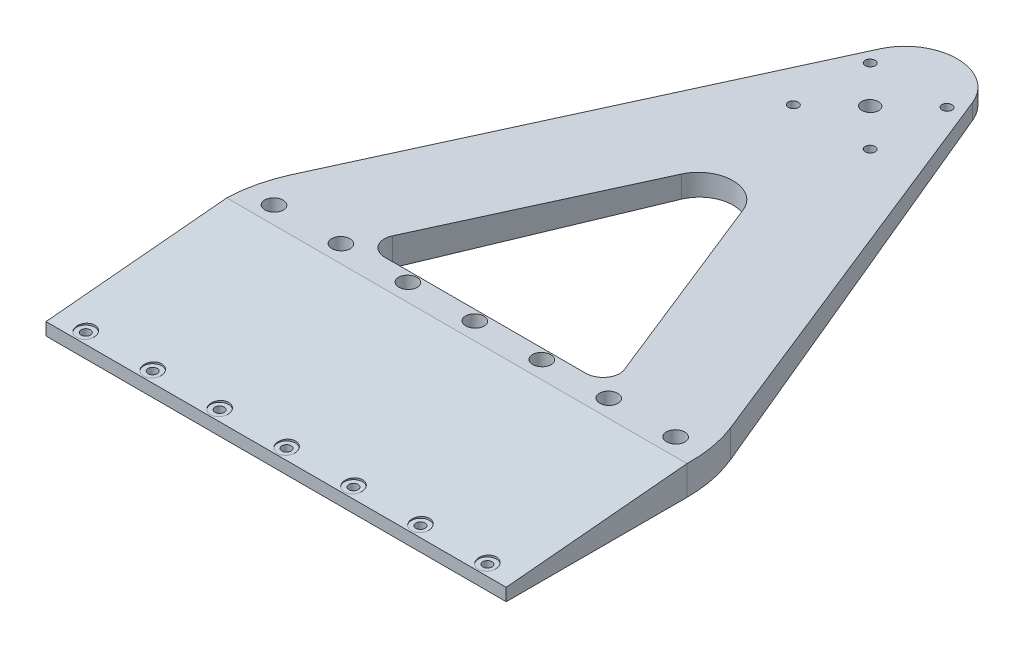
from build123d import *

# Parameters (mm, degrees)
SKETCH1_W           = 139.7
SKETCH1_H           = 63.5
BOSS_EXTRUDE1_DEPTH = 8.89
SKETCH2_R           = 1.4
CUT_EXTRUDE1_DEPTH  = 16.51
BOSS_EXTRUDE2_DEPTH = 8.89
FILLET1_R           = 10.16
FILLET2_R           = 5.08
FILLET3_R           = 43.18
SKETCH4_R           = 1.5
SKETCH4_R_2         = 2.5
CUT_EXTRUDE3_DEPTH  = 11.43
CUT_EXTRUDE6_DEPTH  = 198.882
SKETCH22_R          = 2.75
CUT_EXTRUDE8_DEPTH  = 4.572
SKETCH23_R          = 2.75
CUT_EXTRUDE9_DEPTH  = 4.572


with BuildPart() as part:
    # Sketch1 → Boss-Extrude1 (new body)
    with BuildSketch(Plane(origin=(0, 0, 0), x_dir=(1, 0, 0), z_dir=(0, 1, 0))):
        with Locations((69.85, 31.75)):
            Rectangle(SKETCH1_W, SKETCH1_H)
    extrude(amount=BOSS_EXTRUDE1_DEPTH)

    # Sketch2 → Cut-Extrude1 (cut)
    with BuildSketch(Plane(origin=(0, 8.89, 0), x_dir=(1, 0, 0), z_dir=(0, 1, 0))):
        with Locations((69.85, 60.325)):
            Circle(SKETCH2_R)
        with Locations((69.85, 3.175)):
            Circle(SKETCH2_R)
        with Locations((90.17, 3.175)):
            Circle(SKETCH2_R)
        with Locations((110.49, 3.175)):
            Circle(SKETCH2_R)
        with Locations((130.81, 3.175)):
            Circle(SKETCH2_R)
        with Locations((49.53, 3.175)):
            Circle(SKETCH2_R)
        with Locations((29.21, 3.175)):
            Circle(SKETCH2_R)
        with Locations((8.89, 3.175)):
            Circle(SKETCH2_R)
        with Locations((90.17, 60.325)):
            Circle(SKETCH2_R)
        with Locations((110.49, 60.325)):
            Circle(SKETCH2_R)
        with Locations((130.81, 60.325)):
            Circle(SKETCH2_R)
        with Locations((49.53, 60.325)):
            Circle(SKETCH2_R)
        with Locations((29.21, 60.325)):
            Circle(SKETCH2_R)
        with Locations((8.89, 60.325)):
            Circle(SKETCH2_R)
    extrude(amount=-CUT_EXTRUDE1_DEPTH, mode=Mode.SUBTRACT)


with BuildPart() as body_2:
    # Sketch3 → Boss-Extrude2 (new body)
    with BuildSketch(Plane(origin=(0, 8.89, 0), x_dir=(1, 0, 0), z_dir=(0, 1, 0))):
        with BuildLine():
            Line((31.75, 63.5), (69.85, 154.94))
            Line((69.85, 154.94), (107.95, 63.5))
            Line((107.95, 63.5), (139.7, 63.5))
            Line((139.7, 63.5), (83.917692308, 197.377538462))
            ThreePointArc((83.917692308, 197.377538462), (69.85, 206.756), (55.782307692, 197.377538462))
            Line((55.782307692, 197.377538462), (0, 63.5))
            Line((0, 63.5), (31.75, 63.5))
        make_face()
    extrude(amount=-BOSS_EXTRUDE2_DEPTH)

    # Fillet1
    fillet1_edges = [body_2.edges().sort_by_distance(p)[0] for p in [
        (69.85, 4.445, -154.94),
    ]]
    fillet(fillet1_edges, radius=FILLET1_R)


with BuildPart() as part_1:
    add(part.part)

    # Combine1: union body 2
    add(body_2.part)

    # Fillet2
    fillet2_edges = [part_1.edges().sort_by_distance(p)[0] for p in [
        (31.75, 4.445, -63.5),
        (107.95, 4.445, -63.5),
    ]]
    fillet(fillet2_edges, radius=FILLET2_R)

    # Fillet3
    fillet3_edges = [part_1.edges().sort_by_distance(p)[0] for p in [
        (0, 4.445, -63.5),
        (139.7, 4.445, -63.5),
    ]]
    fillet(fillet3_edges, radius=FILLET3_R)

    # Sketch4 → Cut-Extrude3 (cut)
    with BuildSketch(Plane(origin=(0, 8.89, 0), x_dir=(1, 0, 0), z_dir=(0, 1, 0))):
        with Locations((81.51726189, 192.00726189)):
            Circle(SKETCH4_R)
        with Locations((81.51726189, 168.67273811)):
            Circle(SKETCH4_R)
        with Locations((58.18273811, 192.00726189)):
            Circle(SKETCH4_R)
        with Locations((58.18273811, 168.67273811)):
            Circle(SKETCH4_R)
        with Locations((69.85, 180.34)):
            Circle(SKETCH4_R_2)
    extrude(amount=-CUT_EXTRUDE3_DEPTH, mode=Mode.SUBTRACT)

    # Sketch20 → Cut-Extrude6 (cut)
    with BuildSketch(Plane.ZY):
        Polygon((-54.864, 8.89), (0, 3.81), (0, 8.89), align=None)
        Polygon((-206.756, 4.445), (-54.864, 8.89), (-206.756, 8.89), align=None)
    extrude(amount=-CUT_EXTRUDE6_DEPTH, mode=Mode.SUBTRACT)

    # Sketch22 → Cut-Extrude8 (cut)
    with BuildSketch(Plane(origin=(0, 10.4865712, -0.306881264), x_dir=(1, 0, 0), z_dir=(0, 0.99957207772113, -0.029251691237658497))):
        with Locations((130.81, 60.043812821)):
            Circle(SKETCH22_R)
        with Locations((110.49, 60.043812821)):
            Circle(SKETCH22_R)
        with Locations((90.17, 60.043812821)):
            Circle(SKETCH22_R)
        with Locations((69.85, 60.043812821)):
            Circle(SKETCH22_R)
        with Locations((49.53, 60.043812821)):
            Circle(SKETCH22_R)
        with Locations((29.21, 60.043812821)):
            Circle(SKETCH22_R)
        with Locations((8.89, 60.043812821)):
            Circle(SKETCH22_R)
    extrude(amount=-CUT_EXTRUDE8_DEPTH, mode=Mode.SUBTRACT)

    # Sketch23 → Cut-Extrude9 (cut)
    with BuildSketch(Plane(origin=(0, 3.81, 0), x_dir=(-1, 0, 0), z_dir=(0, -1, 0))):
        with Locations((-8.89, 3.175)):
            Circle(SKETCH23_R)
        with Locations((-29.21, 3.175)):
            Circle(SKETCH23_R)
        with Locations((-49.53, 3.175)):
            Circle(SKETCH23_R)
        with Locations((-69.85, 3.175)):
            Circle(SKETCH23_R)
        with Locations((-90.17, 3.175)):
            Circle(SKETCH23_R)
        with Locations((-110.49, 3.175)):
            Circle(SKETCH23_R)
        with Locations((-130.81, 3.175)):
            Circle(SKETCH23_R)
    extrude(amount=-CUT_EXTRUDE9_DEPTH, mode=Mode.SUBTRACT)


solid = part_1.part
